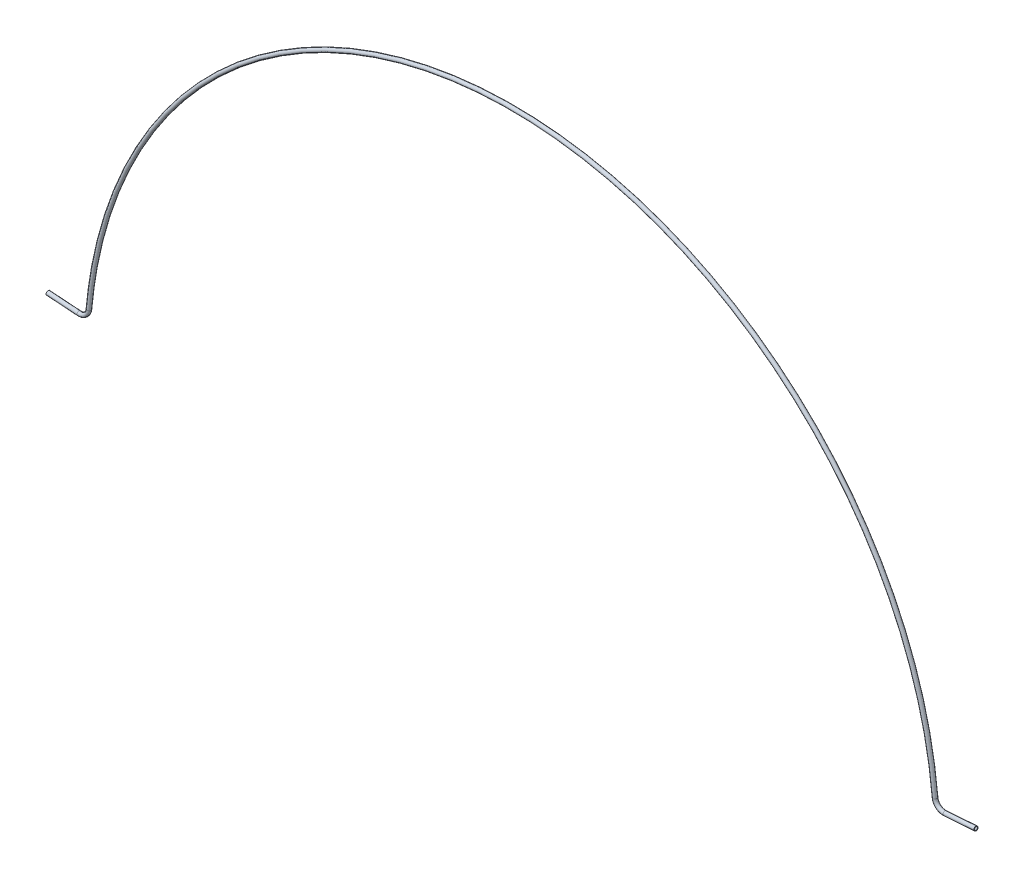
from build123d import *

# Parameters (mm, degrees)
SKETCH2_R   = 2.38125
SKETCH2_R_2 = 1.6764


with BuildPart() as part:
    # Sweep1: sweep along a path in Sketch1
    with BuildLine(Plane(origin=(-579.310835335, -59.57996515, 0), x_dir=(0, -1, 0), z_dir=(0, 0, 1))) as sweep1_path:
        Line((-97.946025709, 1127.971062978), (-95.391089757, 1091.433776617))
        ThreePointArc((-95.391089757, 1091.433776617), (-98.011410229, 1083.459332262), (-105.461633583, 1079.592548826))
        ThreePointArc((-105.461633583, 1079.592548826), (-430.684404824, 917.938086463), (-561.96121515, 579.310835335))
    # Sketch2 → Sweep1 (sweep)
    with BuildSketch(Plane(origin=(0, 0, 0), x_dir=(0, 0, -1), z_dir=(1, 0, 0))):
        with Locations((0, 502.38125)):
            Circle(SKETCH2_R)
        with Locations((0, 502.38125)):
            Circle(SKETCH2_R_2, mode=Mode.SUBTRACT)
    sweep1 = sweep(path=sweep1_path.line)

    # Mirror1: Sweep1 across plane
    add(sweep1.mirror(Plane(origin=(0, 0, 0), x_dir=(0, 0, 1), z_dir=(1, 0, 0))))


solid = part.part
